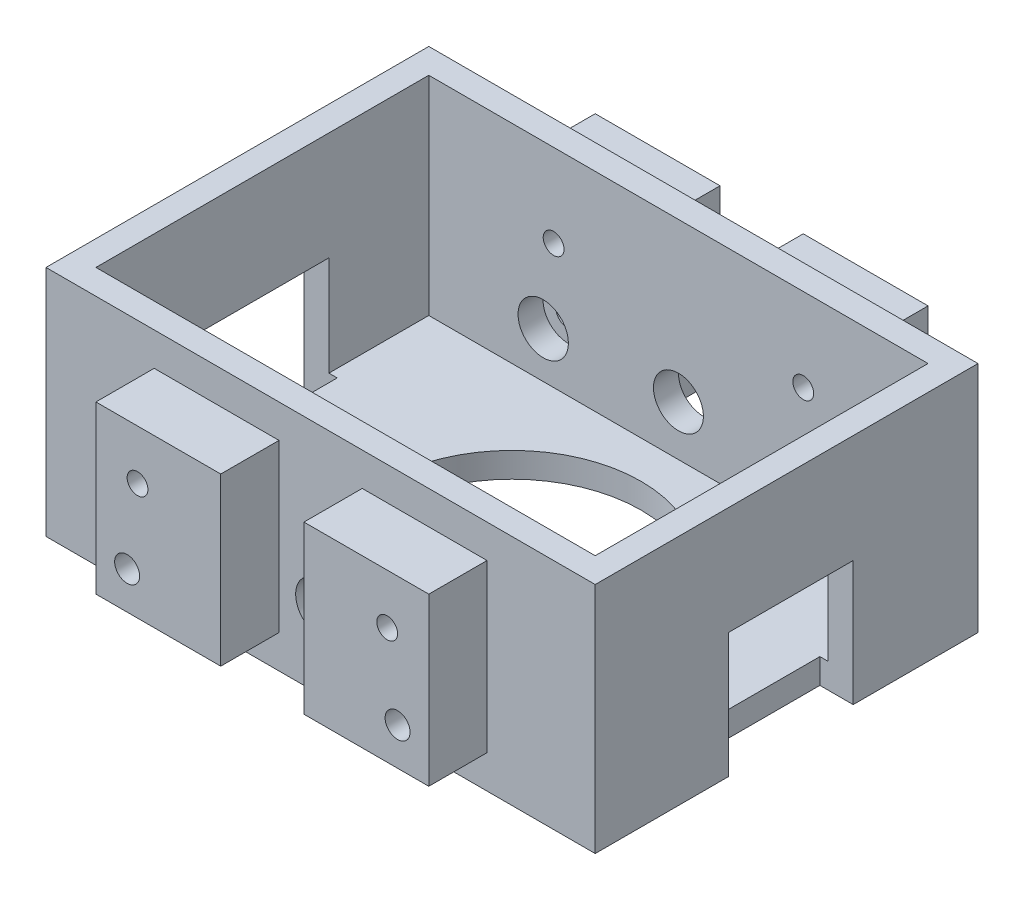
from build123d import *

# Parameters (mm, degrees)
SKETCH1_W               = 66
SKETCH1_H               = 46
BOSS_EXTRUDE2_DEPTH     = 3
SKETCH3_W               = 66
SKETCH3_H               = 46
SKETCH3_W_2             = 60
SKETCH3_H_2             = 40
BOSS_EXTRUDE4_DEPTH     = 25
SKETCH4_W               = 15
SKETCH4_H               = 20
BOSS_EXTRUDE5_DEPTH     = 7
CUT_EXTRUDE1_REACH      = 55
SKETCH5_R               = 1.5
SKETCH5_R_2             = 1.25
SKETCH6_W               = 15
SKETCH6_H               = 20
BOSS_EXTRUDE6_DEPTH     = 7
SKETCH7_R               = 1.5
SKETCH7_R_2             = 1.25
CUT_EXTRUDE2_DEPTH      = 10
CUT_EXTRUDE3_REACH      = 30
SKETCH8_R               = 15.5
SKETCH11_R              = 3
CUT_EXTRUDE6_DEPTH      = 8
CUT_EXTRUDE6_DEPTH_BACK = 54
SKETCH12_R              = 3.025
CUT_EXTRUDE7_DEPTH      = 3
SKETCH14_R              = 3.025
CUT_EXTRUDE8_DEPTH      = 3
SKETCH15_W              = 4
SKETCH15_H              = 15
CUT_EXTRUDE10_DEPTH     = 15


with BuildPart() as part:
    # Sketch1 → Boss-Extrude2 (new body)
    with BuildSketch(Plane(origin=(0, 0, 0), x_dir=(1, 0, 0), z_dir=(0, 1, 0))):
        with Locations((-8.324615879, -17.817795916)):
            Rectangle(SKETCH1_W, SKETCH1_H)
    extrude(amount=BOSS_EXTRUDE2_DEPTH)

    # Sketch3 → Boss-Extrude4 (add)
    with BuildSketch(Plane(origin=(0, 3, 0), x_dir=(1, 0, 0), z_dir=(0, 1, 0))):
        with Locations((-8.324615879, -17.817795916)):
            Rectangle(SKETCH3_W, SKETCH3_H)
        with Locations((-8.324615879, -17.817795916)):
            Rectangle(SKETCH3_W_2, SKETCH3_H_2, mode=Mode.SUBTRACT)
    extrude(amount=BOSS_EXTRUDE4_DEPTH)

    # Sketch4 → Boss-Extrude5 (add)
    with BuildSketch(Plane.XY.offset(40.817795916)):
        with Locations((4.175384121, 14)):
            Rectangle(SKETCH4_W, SKETCH4_H)
        with Locations((-20.824615879, 14)):
            Rectangle(SKETCH4_W, SKETCH4_H)
    extrude(amount=BOSS_EXTRUDE5_DEPTH)

    # Sketch5 → Cut-Extrude1 (cut, up to next)
    with BuildSketch(Plane.XY.offset(47.817795916), mode=Mode.PRIVATE) as cut_extrude1_sk1:
        with Locations((-24.574615879, 8.5)):
            Circle(SKETCH5_R)
    cut_extrude1_tool1 = extrude(cut_extrude1_sk1.sketch, amount=-CUT_EXTRUDE1_REACH, mode=Mode.PRIVATE) & part.part
    add(cut_extrude1_tool1.solids().sort_by_distance((-24.574616, 8.5, 47.817796))[0], mode=Mode.SUBTRACT)
    # Sketch5 → Cut-Extrude1 (cut, up to next)
    with BuildSketch(Plane.XY.offset(47.817795916), mode=Mode.PRIVATE) as cut_extrude1_sk2:
        with Locations((7.925384121, 8.5)):
            Circle(SKETCH5_R)
    cut_extrude1_tool2 = extrude(cut_extrude1_sk2.sketch, amount=-CUT_EXTRUDE1_REACH, mode=Mode.PRIVATE) & part.part
    add(cut_extrude1_tool2.solids().sort_by_distance((7.925384, 8.5, 47.817796))[0], mode=Mode.SUBTRACT)
    # Sketch5 → Cut-Extrude1 (cut, up to next)
    with BuildSketch(Plane.XY.offset(47.817795916), mode=Mode.PRIVATE) as cut_extrude1_sk3:
        with Locations((6.675384121, 18)):
            Circle(SKETCH5_R_2)
    cut_extrude1_tool3 = extrude(cut_extrude1_sk3.sketch, amount=-CUT_EXTRUDE1_REACH, mode=Mode.PRIVATE) & part.part
    add(cut_extrude1_tool3.solids().sort_by_distance((6.675384, 18, 47.817796))[0], mode=Mode.SUBTRACT)
    # Sketch5 → Cut-Extrude1 (cut, up to next)
    with BuildSketch(Plane.XY.offset(47.817795916), mode=Mode.PRIVATE) as cut_extrude1_sk4:
        with Locations((-23.324615879, 18)):
            Circle(SKETCH5_R_2)
    cut_extrude1_tool4 = extrude(cut_extrude1_sk4.sketch, amount=-CUT_EXTRUDE1_REACH, mode=Mode.PRIVATE) & part.part
    add(cut_extrude1_tool4.solids().sort_by_distance((-23.324616, 18, 47.817796))[0], mode=Mode.SUBTRACT)

    # Sketch6 → Boss-Extrude6 (add)
    with BuildSketch(Plane(origin=(0, 0, -5.182204084), x_dir=(-1, 0, 0), z_dir=(0, 0, -1))):
        with Locations((-4.175384121, 14)):
            Rectangle(SKETCH6_W, SKETCH6_H)
        with Locations((20.824615879, 14)):
            Rectangle(SKETCH6_W, SKETCH6_H)
    extrude(amount=BOSS_EXTRUDE6_DEPTH)

    # Sketch7 → Cut-Extrude2 (cut)
    with BuildSketch(Plane(origin=(0, 0, -12.182204084), x_dir=(-1, 0, 0), z_dir=(0, 0, -1))):
        with Locations((-7.925384121, 8.5)):
            Circle(SKETCH7_R)
        with Locations((24.574615879, 8.5)):
            Circle(SKETCH7_R)
        with Locations((23.324615879, 18)):
            Circle(SKETCH7_R_2)
        with Locations((-6.675384121, 18)):
            Circle(SKETCH7_R_2)
    extrude(amount=-CUT_EXTRUDE2_DEPTH, mode=Mode.SUBTRACT)

    # Sketch8 → Cut-Extrude3 (cut, up to next)
    with BuildSketch(Plane(origin=(0, 0, 0), x_dir=(-1, 0, 0), z_dir=(0, -1, 0)), mode=Mode.PRIVATE) as cut_extrude3_sk1:
        with Locations((8.324615879, -17.817795916)):
            Circle(SKETCH8_R)
    cut_extrude3_tool1 = extrude(cut_extrude3_sk1.sketch, amount=-CUT_EXTRUDE3_REACH, mode=Mode.PRIVATE) & part.part
    add(cut_extrude3_tool1.solids().sort_by_distance((-8.324616, 0, 17.817796))[0], mode=Mode.SUBTRACT)

    # Sketch11 → Cut-Extrude6 (cut, two sides)
    with BuildSketch(Plane.XY.offset(40.817795916)) as cut_extrude6_sk:
        with Locations((-8.324615879, 9)):
            Circle(SKETCH11_R)
    extrude(amount=CUT_EXTRUDE6_DEPTH, mode=Mode.SUBTRACT)
    extrude(cut_extrude6_sk.sketch, amount=-CUT_EXTRUDE6_DEPTH_BACK, mode=Mode.SUBTRACT)

    # Sketch12 → Cut-Extrude7 (cut)
    with BuildSketch(Plane(origin=(0, 0, 37.817795916), x_dir=(-1, 0, 0), z_dir=(0, 0, -1))):
        with Locations((24.574615879, 8.5)):
            Circle(SKETCH12_R)
        with Locations((-7.925384121, 8.5)):
            Circle(SKETCH12_R)
    extrude(amount=-CUT_EXTRUDE7_DEPTH, mode=Mode.SUBTRACT)

    # Sketch14 → Cut-Extrude8 (cut)
    with BuildSketch(Plane.XY.offset(-2.182204084)):
        with Locations((-24.574615879, 8.5)):
            Circle(SKETCH14_R)
        with Locations((7.925384121, 8.5)):
            Circle(SKETCH14_R)
    extrude(amount=-CUT_EXTRUDE8_DEPTH, mode=Mode.SUBTRACT)

    # Sketch15 → Cut-Extrude10 (cut)
    with BuildSketch(Plane(origin=(0, 0, 0), x_dir=(-1, 0, 0), z_dir=(0, -1, 0))):
        with Locations((-22.675384121, -17.317795916)):
            Rectangle(SKETCH15_W, SKETCH15_H)
        with Locations((39.324615879, -17.317795916)):
            Rectangle(SKETCH15_W, SKETCH15_H)
    extrude(amount=-CUT_EXTRUDE10_DEPTH, mode=Mode.SUBTRACT)


solid = part.part
